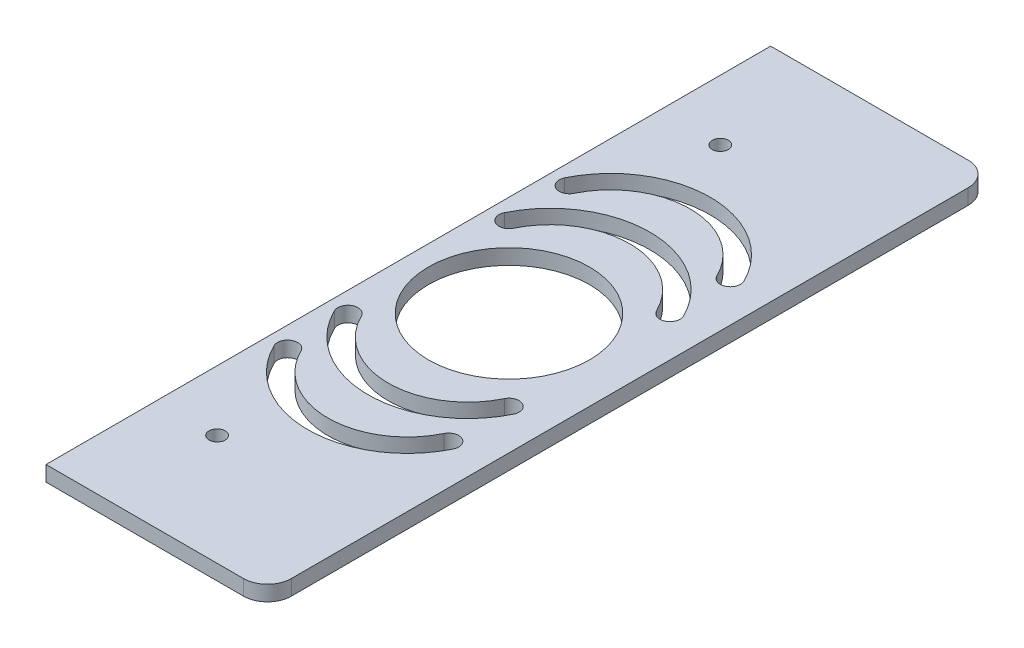
from build123d import *

# Parameters (mm, degrees)
SKETCH1_W           = 139.7
SKETCH1_H           = 457.2
SKETCH1_R           = 50.8
SKETCH1_R_2         = 5.08
BOSS_EXTRUDE1_DEPTH = 9.652
FILLET1_R           = 15.08
CUT_EXTRUDE1_DEPTH  = 9.652


with BuildPart() as part:
    # Sketch1 → Boss-Extrude1 (new body)
    with BuildSketch(Plane(origin=(0, 0, 0), x_dir=(1, 0, 0), z_dir=(0, 1, 0))):
        with Locations((69.85, 228.6)):
            Rectangle(SKETCH1_W, SKETCH1_H)
        with Locations((63.5, 228.6)):
            Circle(SKETCH1_R, mode=Mode.SUBTRACT)
        with Locations((38.1, 69.85)):
            Circle(SKETCH1_R_2, mode=Mode.SUBTRACT)
        with Locations((38.1, 387.35)):
            Circle(SKETCH1_R_2, mode=Mode.SUBTRACT)
    extrude(amount=BOSS_EXTRUDE1_DEPTH)

    # Fillet1
    fillet1_edges = [part.edges().sort_by_distance(p)[0] for p in [
        (139.7, 4.826, -457.2),
        (139.7, 4.826, 0),
    ]]
    fillet(fillet1_edges, radius=FILLET1_R)

    # Sketch3 → Cut-Extrude1 (cut)
    with BuildSketch(Plane.XZ):
        with BuildLine():
            ThreePointArc((18.407865169, -314.71741573), (63.5, -342.9), (108.592134831, -314.71741573))
            ThreePointArc((108.592134831, -314.71741573), (117.08258427, -311.792134831), (120.007865169, -320.28258427))
            ThreePointArc((120.007865169, -320.28258427), (63.5, -355.6), (6.992134831, -320.28258427))
            ThreePointArc((6.992134831, -320.28258427), (9.91741573, -311.792134831), (18.407865169, -314.71741573))
        make_face()
        with BuildLine():
            ThreePointArc((6.992134831, -282.18258427), (63.5, -317.5), (120.007865169, -282.18258427))
            ThreePointArc((120.007865169, -282.18258427), (117.08258427, -273.692134831), (108.592134831, -276.61741573))
            ThreePointArc((108.592134831, -276.61741573), (63.5, -304.8), (18.407865169, -276.61741573))
            ThreePointArc((18.407865169, -276.61741573), (9.91741573, -273.692134831), (6.992134831, -282.18258427))
        make_face()
        with BuildLine():
            ThreePointArc((6.992134831, -136.91741573), (63.5, -101.6), (120.007865169, -136.91741573))
            ThreePointArc((120.007865169, -136.91741573), (117.08258427, -145.407865169), (108.592134831, -142.48258427))
            ThreePointArc((108.592134831, -142.48258427), (63.5, -114.3), (18.407865169, -142.48258427))
            ThreePointArc((18.407865169, -142.48258427), (9.91741573, -145.407865169), (6.992134831, -136.91741573))
        make_face()
        with BuildLine():
            ThreePointArc((6.992134831, -175.01741573), (63.5, -139.7), (120.007865169, -175.01741573))
            ThreePointArc((120.007865169, -175.01741573), (117.08258427, -183.507865169), (108.592134831, -180.58258427))
            ThreePointArc((108.592134831, -180.58258427), (63.5, -152.4), (18.407865169, -180.58258427))
            ThreePointArc((18.407865169, -180.58258427), (9.91741573, -183.507865169), (6.992134831, -175.01741573))
        make_face()
    extrude(amount=-CUT_EXTRUDE1_DEPTH, mode=Mode.SUBTRACT)


solid = part.part
